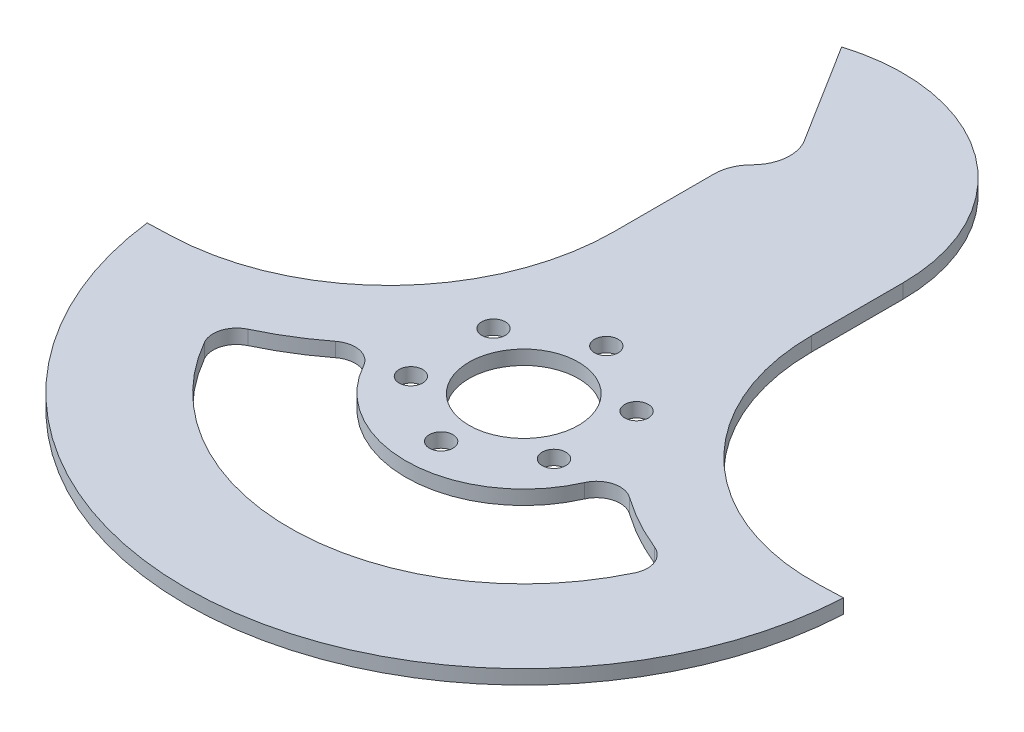
from build123d import *

# Parameters (mm, degrees)
BOSS_EXTRUDE1_DEPTH = 3.02
CUT_EXTRUDE2_DEPTH  = 4.02
FILLET6_R           = 5
SKETCH7_R           = 25
BOSS_EXTRUDE5_DEPTH = 3.02
FILLET7_R           = 5
SKETCH8_R           = 11.6
CUT_EXTRUDE3_DEPTH  = 4.0200001
SKETCH10_R          = 2.5
CUT_EXTRUDE4_DEPTH  = 4.0200001


with BuildPart() as part:
    # Sketch1 → Boss-Extrude1 (new body)
    with BuildSketch(Plane(origin=(0, 0, 0), x_dir=(1, 0, 0), z_dir=(0, 1, 0))):
        with BuildLine():
            Line((-29.785324721, 97.135958487), (-16.519810347, 75.945721858))
            ThreePointArc((-16.519810347, 75.945721858), (-15.347350146, 70.779086196), (-17.648053563, 66.006712491))
            ThreePointArc((-17.648053563, 66.006712491), (-19.388749036, 63.401577615), (-20, 60.328611505))
            Line((-20, 60.328611505), (-20, 39.154861291))
            ThreePointArc((-20, 39.154861291), (-33.397395417, 5.995144025), (-66.069350322, -8.551347504))
            Line((-66.069350322, -8.551347504), (-71.066304458, -8.725844988))
            ThreePointArc((-71.066304458, -8.725844988), (2.498803964, -71.556383215), (71.501874688, -3.747254467))
            Line((71.501874688, -3.747254467), (66.504920553, -3.921751951))
            ThreePointArc((66.504920553, -3.921751951), (33.721031142, 8.662804123), (20, 40.987527801))
            Line((20, 40.987527801), (20, 60.328611505))
            ThreePointArc((20, 60.328611505), (4.388325927, 91.285675923), (-29.785324721, 97.135958487))
        make_face()
    extrude(amount=BOSS_EXTRUDE1_DEPTH)

    # Sketch6 → Cut-Extrude2 (cut, through all)
    with BuildSketch(Plane(origin=(0, 3.02, 0), x_dir=(1, 0, 0), z_dir=(0, 1, 0))):
        with BuildLine():
            ThreePointArc((-45.588380428, -19.541227443), (1.807988114, -49.567037222), (46.890896023, -16.167989057))
            ThreePointArc((46.890896023, -16.167989057), (28.340616971, -6.479645741), (14.25203647, 8.995778278))
            ThreePointArc((14.25203647, 8.995778278), (3.327119381, -16.521950459), (-16.623047064, 2.77828664))
            ThreePointArc((-16.623047064, 2.77828664), (-29.443436546, -10.538704339), (-45.588380428, -19.541227443))
        make_face()
    extrude(amount=-CUT_EXTRUDE2_DEPTH, mode=Mode.SUBTRACT)

    # Fillet6
    fillet6_edges = [part.edges().sort_by_distance(p)[0] for p in [
        (-45.588380428, 1.51, 19.541227443),
        (46.890896023, 1.51, 16.167989057),
    ]]
    fillet(fillet6_edges, radius=FILLET6_R)

    # Sketch7 → Boss-Extrude5 (add)
    with BuildSketch(Plane(origin=(0, 3.02, 0), x_dir=(1, 0, 0), z_dir=(0, 1, 0))):
        Circle(SKETCH7_R)
    extrude(amount=-BOSS_EXTRUDE5_DEPTH)

    # Fillet7
    fillet7_edges = [part.edges().sort_by_distance(p)[0] for p in [
        (24.755757684, 1.51, 3.486038077),
        (-24.252747569, 1.51, 6.066649432),
    ]]
    fillet(fillet7_edges, radius=FILLET7_R)

    # Sketch8 → Cut-Extrude3 (cut, through all)
    with BuildSketch(Plane(origin=(0, 3.02, 0), x_dir=(1, 0, 0), z_dir=(0, 1, 0))):
        with Locations((0.168160547, -0.172559626)):
            Circle(SKETCH8_R)
    extrude(amount=-CUT_EXTRUDE3_DEPTH, mode=Mode.SUBTRACT)

    # Sketch10 → Cut-Extrude4 (cut, through all)
    with BuildSketch(Plane(origin=(0, 3.02, 0), x_dir=(1, 0, 0), z_dir=(0, 1, 0))):
        with Locations((0.168160547, -17.672559626)):
            Circle(SKETCH10_R)
        with Locations((-14.987284019, -8.922559626)):
            Circle(SKETCH10_R)
        with Locations((-14.987284019, 8.577440374)):
            Circle(SKETCH10_R)
        with Locations((0.168160547, 17.327440374)):
            Circle(SKETCH10_R)
        with Locations((15.323605113, 8.577440374)):
            Circle(SKETCH10_R)
        with Locations((15.323605113, -8.922559626)):
            Circle(SKETCH10_R)
    extrude(amount=-CUT_EXTRUDE4_DEPTH, mode=Mode.SUBTRACT)


solid = part.part
